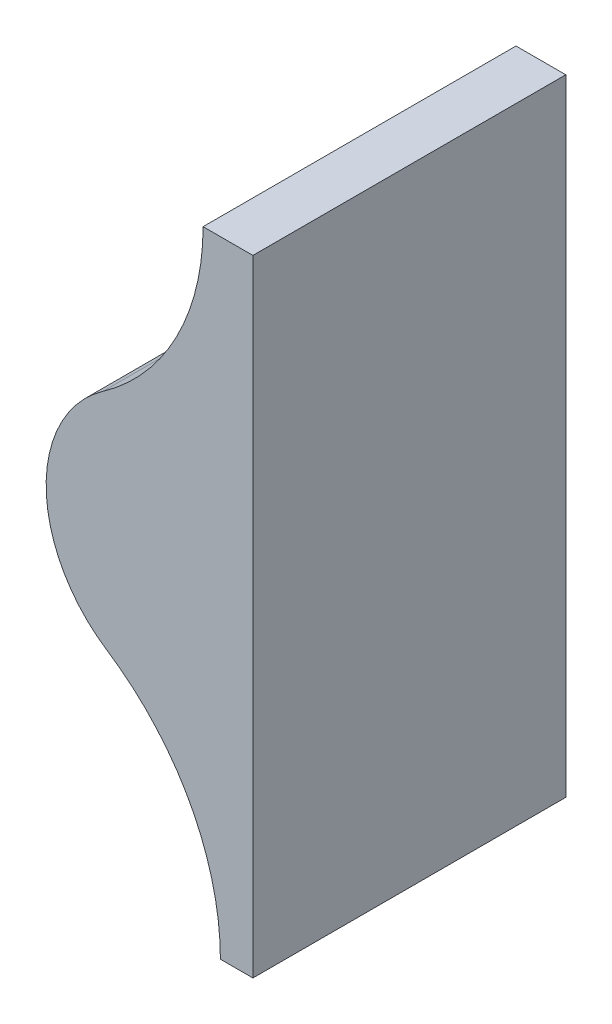
from build123d import *

# Parameters (mm, degrees)
BOSS_EXTRUDE1_DEPTH = 76.2


with BuildPart() as part:
    # Sketch1 → Boss-Extrude1 (new body)
    with BuildSketch(Plane.XY):
        with BuildLine():
            Line((0, 0), (0, 152.4))
            Line((0, 152.4), (-12.12968568, 152.4))
            ThreePointArc((-12.12968568, 152.4), (-18.574227405, 125.991216696), (-36.459022154, 105.51952721))
            ThreePointArc((-36.459022154, 105.51952721), (-50.347627866, 78.240075602), (-35.61642966, 51.406260217))
            ThreePointArc((-35.61642966, 51.406260217), (-15.280490274, 29.197707061), (-7.914068731, 0))
            Line((-7.914068731, 0), (0, 0))
        make_face()
    extrude(amount=BOSS_EXTRUDE1_DEPTH)


solid = part.part
